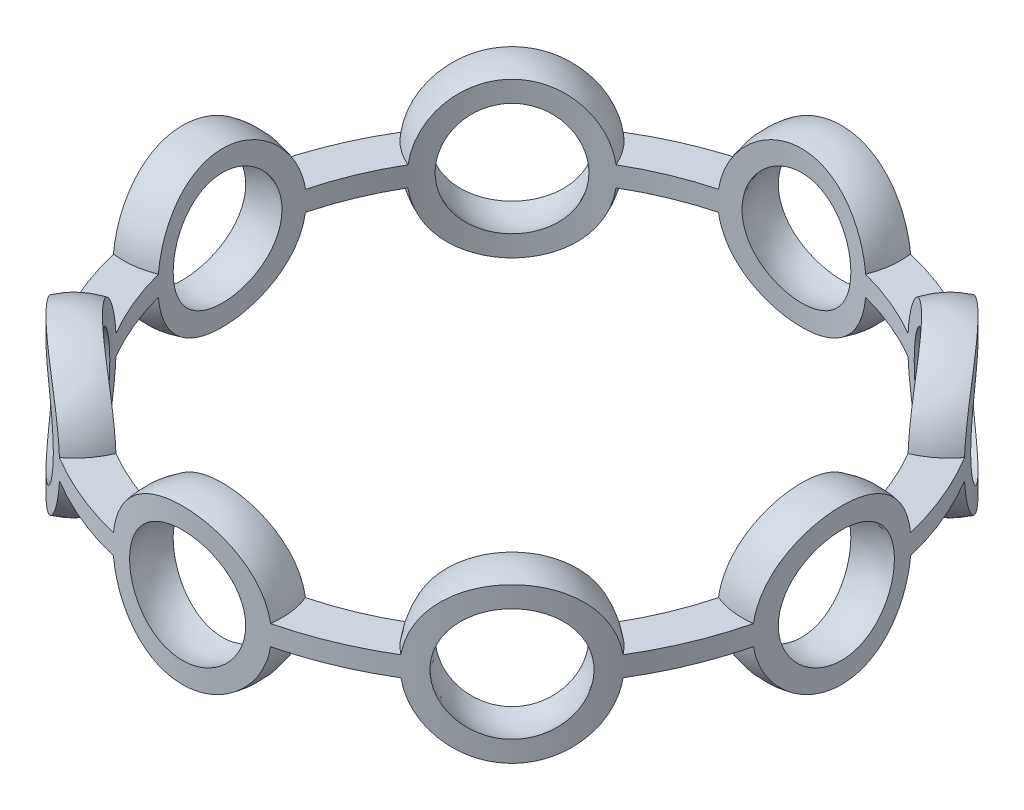
from build123d import *

# Parameters (mm, degrees)
SKETCH1_R           = 16.5
SKETCH1_R_2         = 14.5
BOSS_EXTRUDE2_DEPTH = 4
CIRPATTERN10_COUNT  = 8


with BuildPart() as part:
    # Sketch1 → Boss-Extrude2 (new body, symmetric)
    with BuildSketch(Plane(origin=(0, 0, 0), x_dir=(1, 0, 0), z_dir=(0, 1, 0))):
        Circle(SKETCH1_R)
        Circle(SKETCH1_R_2, mode=Mode.SUBTRACT)
    extrude(amount=BOSS_EXTRUDE2_DEPTH, both=True)

    # Sketch7 → Cut-Revolve7 (revolve, cut)
    with BuildSketch(Plane.XY):
        with BuildLine():
            ThreePointArc((-15.5, -3), (-12.5, 0), (-15.5, 3))
            Line((-15.5, 3), (-15.5, -3))
        make_face()
        with BuildLine():
            Line((-8.531373033, 4.64514597), (-15.5, 4.64514597))
            Line((-15.5, 4.64514597), (-15.5, 4))
            ThreePointArc((-15.5, 4), (-12.854248689, 3), (-11.531373033, 0.5))
            Line((-11.531373033, 0.5), (-8.531373033, 0.5))
            Line((-8.531373033, 0.5), (-8.531373033, 4.64514597))
        make_face()
        with BuildLine():
            Line((-8.531373033, -0.5), (-11.531373033, -0.5))
            ThreePointArc((-11.531373033, -0.5), (-12.854248689, -3), (-15.5, -4))
            Line((-15.5, -4), (-15.5, -4.64514597))
            Line((-15.5, -4.64514597), (-8.531373033, -4.64514597))
            Line((-8.531373033, -4.64514597), (-8.531373033, -0.5))
        make_face()
    cut_revolve7 = revolve(axis=Axis((-15.5, 4.64514597, 0), (0, -1, 0)), mode=Mode.SUBTRACT)

    # CirPattern10: Cut-Revolve7 ×8 about axis
    cirpattern10_axis = Axis((0, 0, 0), (0, 1, 0))
    for i in range(1, CIRPATTERN10_COUNT):
        add(cut_revolve7.rotate(cirpattern10_axis, i * 360 / CIRPATTERN10_COUNT), mode=Mode.SUBTRACT)


solid = part.part
